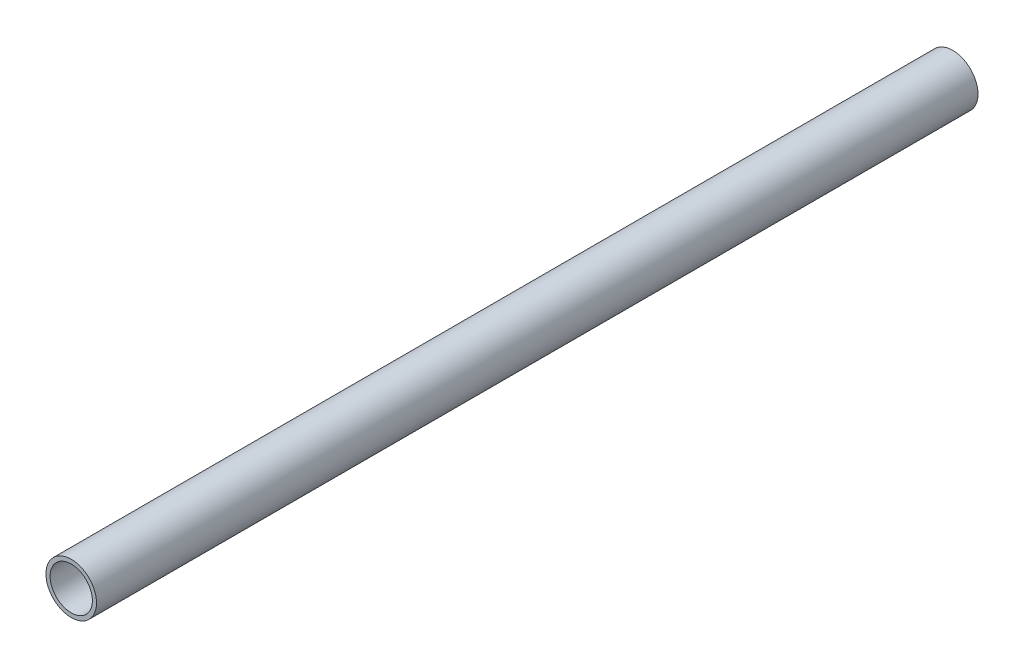
from build123d import *

# Parameters (mm, degrees)
SKETCH1_R           = 24.13
SKETCH1_R_2         = 20.193
BOSS_EXTRUDE1_DEPTH = 841.375


with BuildPart() as part:
    # Sketch1 → Boss-Extrude1 (new body)
    with BuildSketch(Plane.XY):
        Circle(SKETCH1_R)
        Circle(SKETCH1_R_2, mode=Mode.SUBTRACT)
    extrude(amount=BOSS_EXTRUDE1_DEPTH)


solid = part.part
